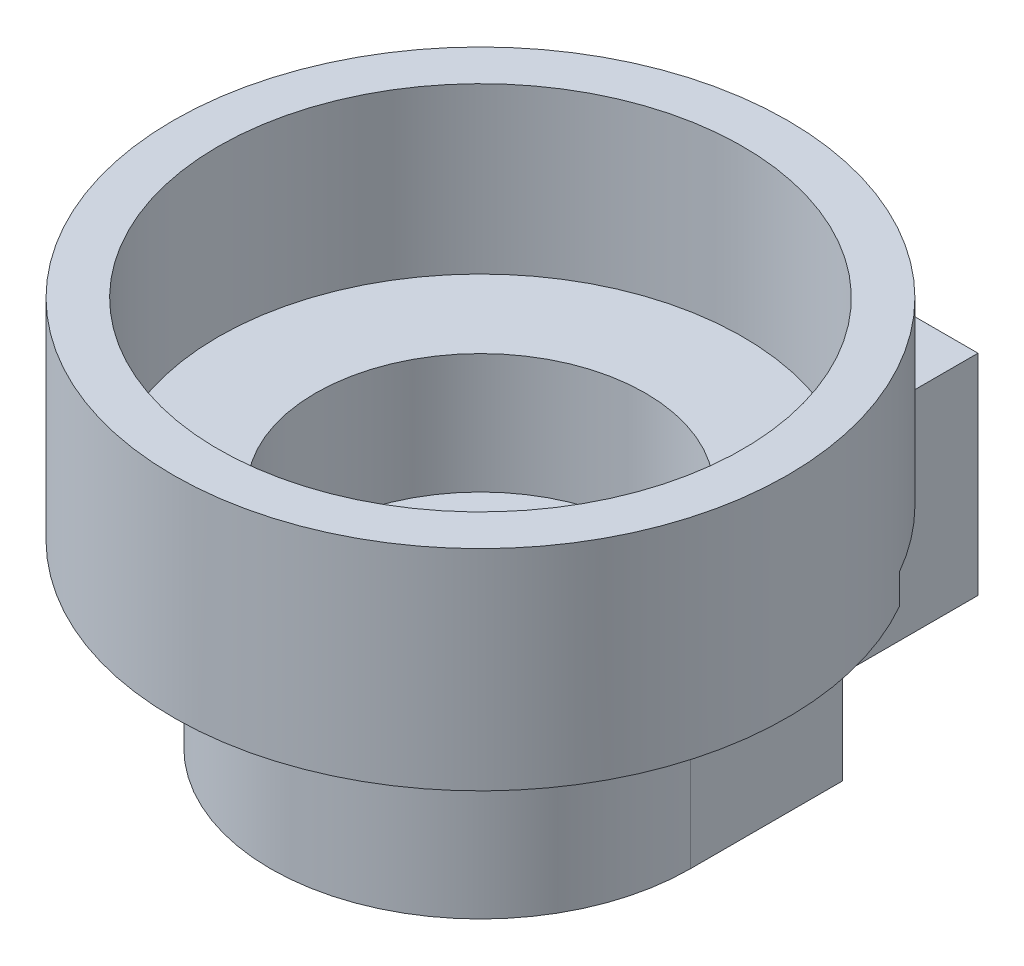
from build123d import *

# Parameters (mm, degrees)
SKETCH2_R           = 4.15
CUT_EXTRUDE1_DEPTH  = 26.999999876
BOSS_EXTRUDE1_DEPTH = 12
SKETCH4_R           = 4.62499994
CUT_EXTRUDE2_DEPTH  = 10.62
SKETCH5_R           = 2
CUT_EXTRUDE3_DEPTH  = 22.86
BOSS_EXTRUDE2_DEPTH = 2
SKETCH7_W           = 15.24
SKETCH7_H           = 13.999999876
CUT_EXTRUDE4_DEPTH  = 12.699999968


with BuildPart() as part:
    # Sketch1 → Revolve1 (revolve)
    with BuildSketch(Plane.XY):
        Polygon((0, 0), (-14.000000152, 0), (-14.000000152, 11.999999876), (-20.500000052, 11.999999876), (-20.500000052, 25.999999876), (-17.500000052, 25.999999876), (-17.500000052, 14.999999876), (-11.000000152, 14.999999876), (-11.000000152, 6.999999906), (0, 6.999999906), align=None)
    revolve(axis=Axis((0, 6.999999906, 0), (0, -1, 0)))

    # Sketch2 → Cut-Extrude1 (cut, through all)
    with BuildSketch(Plane.XZ):
        Circle(SKETCH2_R)
    extrude(amount=-CUT_EXTRUDE1_DEPTH, mode=Mode.SUBTRACT)

    # Sketch3 → Boss-Extrude1 (add)
    with BuildSketch(Plane.XZ.offset(-11.999999876)):
        with BuildLine():
            Line((-14.000000152, 0), (-14.000000152, -25.4))
            Line((-14.000000152, -25.4), (14.000000152, -25.4))
            Line((14.000000152, -25.4), (14.000000152, 0))
            ThreePointArc((14.000000152, 0), (0, -14.000000152), (-14.000000152, 0))
        make_face()
    extrude(amount=BOSS_EXTRUDE1_DEPTH)

    # Sketch4 → Cut-Extrude2 (cut)
    with BuildSketch(Plane.XZ):
        with Locations((0, -18.1)):
            Circle(SKETCH4_R)
    extrude(amount=-CUT_EXTRUDE2_DEPTH, mode=Mode.SUBTRACT)

    # Sketch5 → Cut-Extrude3 (cut)
    with BuildSketch(Plane.ZY.offset(14.000000152)):
        with Locations((-18.1, 6.000000096)):
            Circle(SKETCH5_R)
    extrude(amount=-CUT_EXTRUDE3_DEPTH, mode=Mode.SUBTRACT)

    # Sketch6 → Boss-Extrude2 (add)
    with BuildSketch(Plane(origin=(0, 11.999999876, 0), x_dir=(1, 0, 0), z_dir=(0, 1, 0))):
        with BuildLine():
            Line((14.000000152, 14.974979061), (14.000000152, 25.4))
            Line((14.000000152, 25.4), (-14.000000152, 25.4))
            Line((-14.000000152, 25.4), (-14.000000152, 14.974979061))
            ThreePointArc((-14.000000152, 14.974979061), (0, 20.500000052), (14.000000152, 14.974979061))
        make_face()
    extrude(amount=BOSS_EXTRUDE2_DEPTH)

    # Sketch7 → Cut-Extrude4 (cut)
    with BuildSketch(Plane.ZY.offset(20.500000052)):
        with Locations((-17.78, 6.999999938)):
            Rectangle(SKETCH7_W, SKETCH7_H)
    cut_extrude4 = extrude(amount=-CUT_EXTRUDE4_DEPTH, mode=Mode.SUBTRACT)

    # Mirror1: Cut-Extrude4 across plane
    add(cut_extrude4.mirror(Plane(origin=(0, 0, 0), x_dir=(0, 0, 1), z_dir=(1, 0, 0))), mode=Mode.SUBTRACT)


solid = part.part
